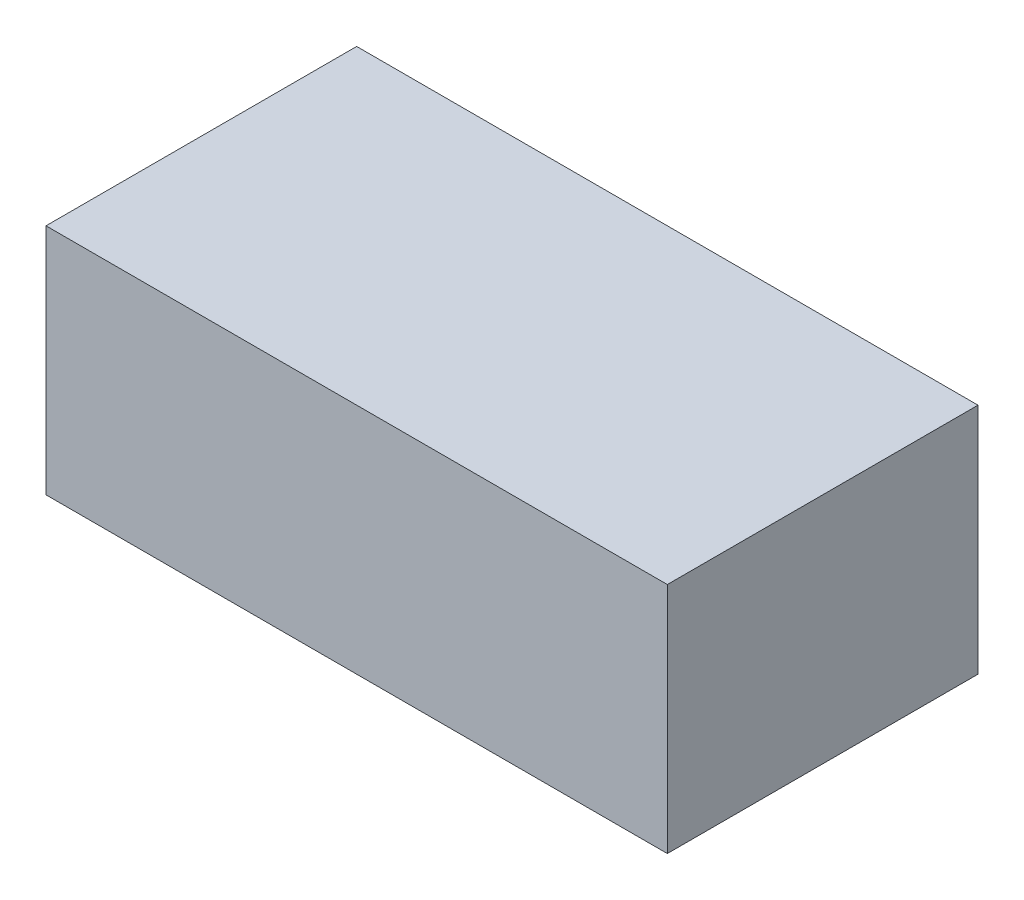
from build123d import *

# Parameters (mm, degrees)
SKETCH_1_W      = 160
SKETCH_1_H      = 80
EXTRUDE_1_DEPTH = 60


with BuildPart() as part:
    # Эскиз1 → Бобышка-Вытянуть1 (new body)
    with BuildSketch(Plane(origin=(0, 0, 0), x_dir=(1, 0, 0), z_dir=(0, 1, 0))):
        Rectangle(SKETCH_1_W, SKETCH_1_H)
    extrude(amount=EXTRUDE_1_DEPTH)


solid = part.part
